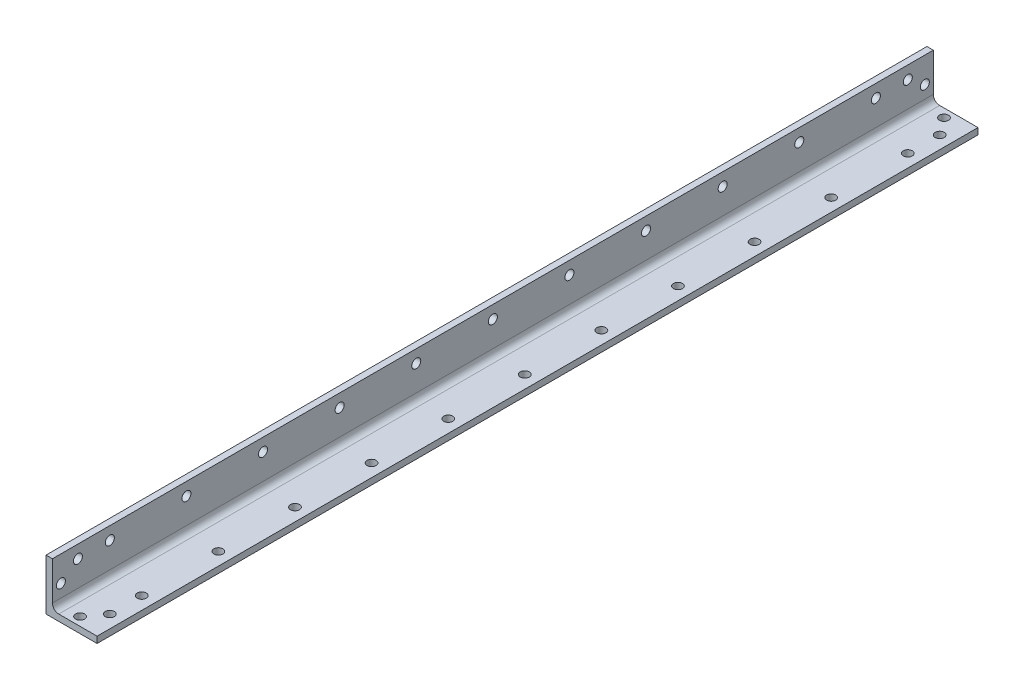
from build123d import *

# Parameters (mm, degrees)
BOSS_EXTRUDE1_DEPTH = 219.075
FILLET1_R           = 3.175
SKETCH2_R           = 2.25
CUT_EXTRUDE1_DEPTH  = 4.175


with BuildPart() as part:
    # Sketch1 → Boss-Extrude1 (new body, symmetric)
    with BuildSketch(Plane.XY):
        Polygon((0, 25.4), (0, 0), (25.4, 0), (25.4, 3.175), (3.175, 3.175), (3.175, 25.4), align=None)
    extrude(amount=BOSS_EXTRUDE1_DEPTH, both=True)

    # Fillet1
    fillet1_edges = [part.edges().sort_by_distance(p)[0] for p in [
        (3.175, 3.175, 0),
    ]]
    fillet(fillet1_edges, radius=FILLET1_R)

    # Sketch2 → Cut-Extrude1 (cut, through all)
    with BuildSketch(Plane(origin=(3.175, 0, 0), x_dir=(0, 0, -1), z_dir=(1, 0, 0))):
        with Locations((-214.841666667, 12.7)):
            Circle(SKETCH2_R)
        with Locations((-206.375, 19.05)):
            Circle(SKETCH2_R)
        with Locations((214.841666667, 12.7)):
            Circle(SKETCH2_R)
        with Locations((206.375, 19.05)):
            Circle(SKETCH2_R)
        with Locations((-190.5, 19.05)):
            Circle(SKETCH2_R)
        with Locations((-152.4, 19.05)):
            Circle(SKETCH2_R)
        with Locations((-114.3, 19.05)):
            Circle(SKETCH2_R)
        with Locations((-76.2, 19.05)):
            Circle(SKETCH2_R)
        with Locations((-38.1, 19.05)):
            Circle(SKETCH2_R)
        with Locations((0, 19.05)):
            Circle(SKETCH2_R)
        with Locations((38.1, 19.05)):
            Circle(SKETCH2_R)
        with Locations((76.2, 19.05)):
            Circle(SKETCH2_R)
        with Locations((114.3, 19.05)):
            Circle(SKETCH2_R)
        with Locations((152.4, 19.05)):
            Circle(SKETCH2_R)
        with Locations((190.5, 19.05)):
            Circle(SKETCH2_R)
    cut_extrude1 = extrude(amount=-CUT_EXTRUDE1_DEPTH, mode=Mode.SUBTRACT)

    # Mirror1: Cut-Extrude1 across plane
    add(cut_extrude1.mirror(Plane(origin=(0, 0, 0), x_dir=(0, 0, 1), z_dir=(0.707106781, -0.707106781, 0))), mode=Mode.SUBTRACT)


solid = part.part
